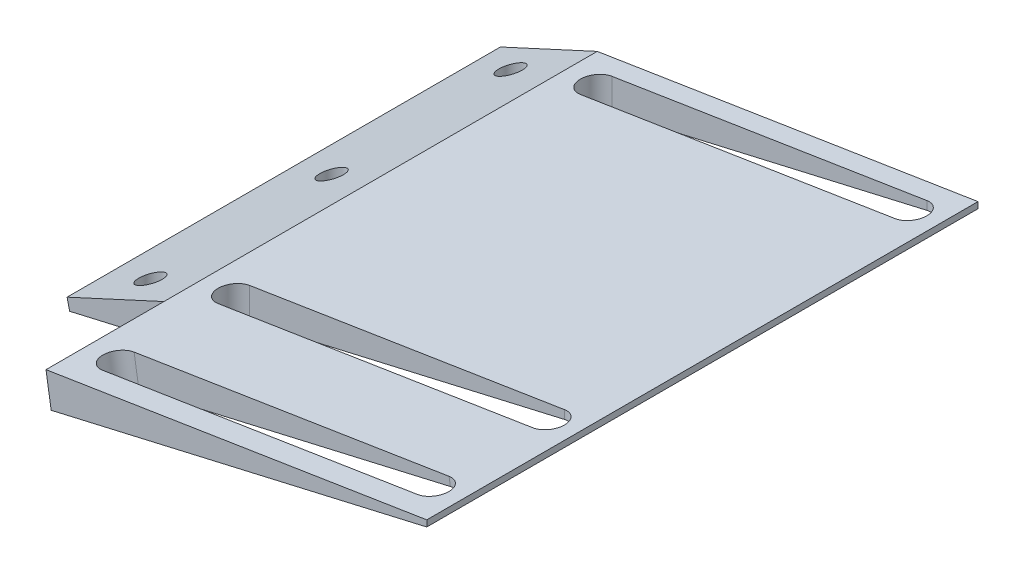
from build123d import *

# Parameters (mm, degrees)
BOSS_EXTRUDE1_DEPTH     = 110
CUT_EXTRUDE1_DEPTH      = 1
CUT_EXTRUDE1_DEPTH_BACK = 111
SKETCH4_R               = 3
CUT_EXTRUDE2_DEPTH      = 1
CUT_EXTRUDE2_DEPTH_BACK = 43.893018073
BOSS_EXTRUDE2_DEPTH     = 30
SKETCH6_W               = 26.1276751
SKETCH6_H               = 29.954556473
CUT_EXTRUDE3_DEPTH      = 19.975306871
CUT_EXTRUDE3_DEPTH_BACK = 30.07458706


with BuildPart() as part:
    # Sketch1 → Boss-Extrude1 (new body)
    with BuildSketch(Plane.XY):
        Polygon((0, 0), (-142.475314215, -32.893018073), (-143.119166497, -30.104187448), (-118.522600871, -18.772135805), align=None)
    extrude(amount=BOSS_EXTRUDE1_DEPTH)

    # Sketch2 → Cut-Extrude1 (cut, two sides)
    with BuildSketch(Plane.XY.offset(110)) as cut_extrude1_sk:
        Polygon((-21.820404963, -3.456012628), (-21.820404963, -5.037637423), (0, 0), align=None)
    extrude(amount=CUT_EXTRUDE1_DEPTH, mode=Mode.SUBTRACT)
    extrude(cut_extrude1_sk.sketch, amount=-CUT_EXTRUDE1_DEPTH_BACK, mode=Mode.SUBTRACT)

    # Sketch4 → Cut-Extrude2 (cut, two sides)
    with BuildSketch(Plane(origin=(0, 10, 0), x_dir=(1, 0, 0), z_dir=(0, 1, 0))) as cut_extrude2_sk:
        with Locations((-130.995623221, -101)):
            Circle(SKETCH4_R)
        with Locations((-131.538244407, -9)):
            Circle(SKETCH4_R)
        with Locations((-130.995623221, -55)):
            Circle(SKETCH4_R)
        with BuildLine():
            Line((-29.820404963, -105), (-109.820404963, -105))
            ThreePointArc((-109.820404963, -105), (-113.820404963, -101), (-109.820404963, -97))
            Line((-109.820404963, -97), (-29.820404963, -97))
            ThreePointArc((-29.820404963, -97), (-25.820404963, -101), (-29.820404963, -105))
        make_face()
        with BuildLine():
            Line((-29.820404963, -5), (-109.820404963, -5))
            ThreePointArc((-109.820404963, -5), (-113.820404963, -9), (-109.820404963, -13))
            Line((-109.820404963, -13), (-29.820404963, -13))
            ThreePointArc((-29.820404963, -13), (-25.820404963, -9), (-29.820404963, -5))
        make_face()
    extrude(amount=CUT_EXTRUDE2_DEPTH, mode=Mode.SUBTRACT)
    extrude(cut_extrude2_sk.sketch, amount=-CUT_EXTRUDE2_DEPTH_BACK, mode=Mode.SUBTRACT)

    # Sketch5 → Boss-Extrude2 (add)
    with BuildSketch(Plane.XY.offset(110)):
        Polygon((-142.475314215, -32.893018073), (-21.820404963, -5.037637423), (-21.820404963, -3.456012628), (-118.522600871, -18.772135805), (-143.119166497, -30.104187448), align=None)
    extrude(amount=BOSS_EXTRUDE2_DEPTH)

    # Sketch6 → Cut-Extrude3 (cut, two sides)
    with BuildSketch(Plane(origin=(0, 0, 0), x_dir=(0.987688341, 0.156434465, 0), z_dir=(-0.156434465, 0.987688341, 0))) as cut_extrude3_sk:
        with BuildLine():
            Line((-30.192120061, -134.324079108), (-111.189330125, -134.324079108))
            ThreePointArc((-111.189330125, -134.324079108), (-115.189330125, -130.324079108), (-111.189330125, -126.324079108))
            Line((-111.189330125, -126.324079108), (-30.192120061, -126.324079108))
            ThreePointArc((-30.192120061, -126.324079108), (-26.192120061, -130.324079108), (-30.192120061, -134.324079108))
        make_face()
        with Locations((-133.06383755, -125.022721764)):
            Rectangle(SKETCH6_W, SKETCH6_H)
    extrude(amount=CUT_EXTRUDE3_DEPTH, mode=Mode.SUBTRACT)
    extrude(cut_extrude3_sk.sketch, amount=-CUT_EXTRUDE3_DEPTH_BACK, mode=Mode.SUBTRACT)


solid = part.part
